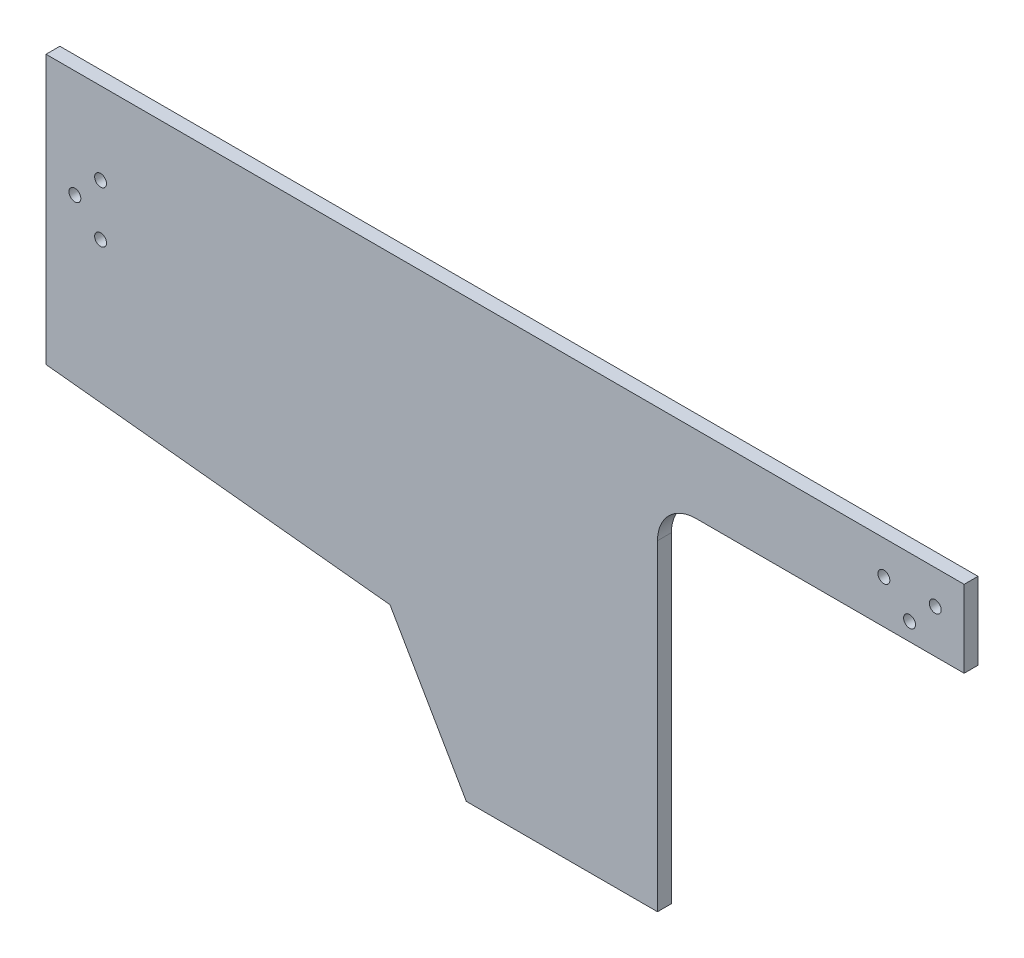
from build123d import *

# Parameters (mm, degrees)
SKETCH1_R           = 1.85
BOSS_EXTRUDE1_DEPTH = 4.318


with BuildPart() as part:
    # Sketch1 → Boss-Extrude1 (new body)
    with BuildSketch(Plane.XY):
        with BuildLine():
            Line((47.48, 175), (47.48, 74.903475932))
            Line((47.48, 74.903475932), (-12.077446035, 74.903475932))
            Line((-12.077446035, 74.903475932), (-35.842451234, 116.06567238))
            Line((-35.842451234, 116.06567238), (-143, 127.288973426))
            Line((-143, 127.288973426), (-143, 211))
            Line((-143, 211), (143, 211))
            Line((143, 211), (143, 187))
            Line((143, 187), (59.48, 187))
            ThreePointArc((59.48, 187), (50.994718626, 183.485281374), (47.48, 175))
        make_face()
        with Locations((-134, 177.5)):
            Circle(SKETCH1_R, mode=Mode.SUBTRACT)
        with Locations((-126, 169.5)):
            Circle(SKETCH1_R, mode=Mode.SUBTRACT)
        with Locations((-126, 185.5)):
            Circle(SKETCH1_R, mode=Mode.SUBTRACT)
        with Locations((118, 200.5)):
            Circle(SKETCH1_R, mode=Mode.SUBTRACT)
        with Locations((126, 192.5)):
            Circle(SKETCH1_R, mode=Mode.SUBTRACT)
        with Locations((134, 200.5)):
            Circle(SKETCH1_R, mode=Mode.SUBTRACT)
    extrude(amount=BOSS_EXTRUDE1_DEPTH)


solid = part.part
